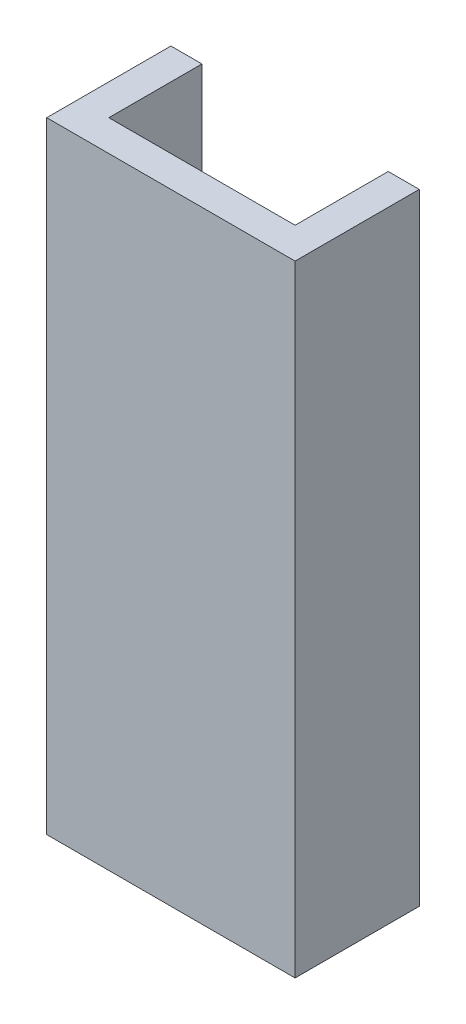
from build123d import *

# Parameters (mm, degrees)
BOSS_EXTRUDE1_DEPTH = 100


with BuildPart() as part:
    # Sketch1 → Boss-Extrude1 (new body)
    with BuildSketch(Plane(origin=(0, 0, 0), x_dir=(1, 0, 0), z_dir=(0, 1, 0))):
        Polygon((-20, 0), (20, 0), (20, 20), (15, 20), (15, 5), (-15, 5), (-15, 20), (-20, 20), align=None)
    extrude(amount=BOSS_EXTRUDE1_DEPTH)


solid = part.part
